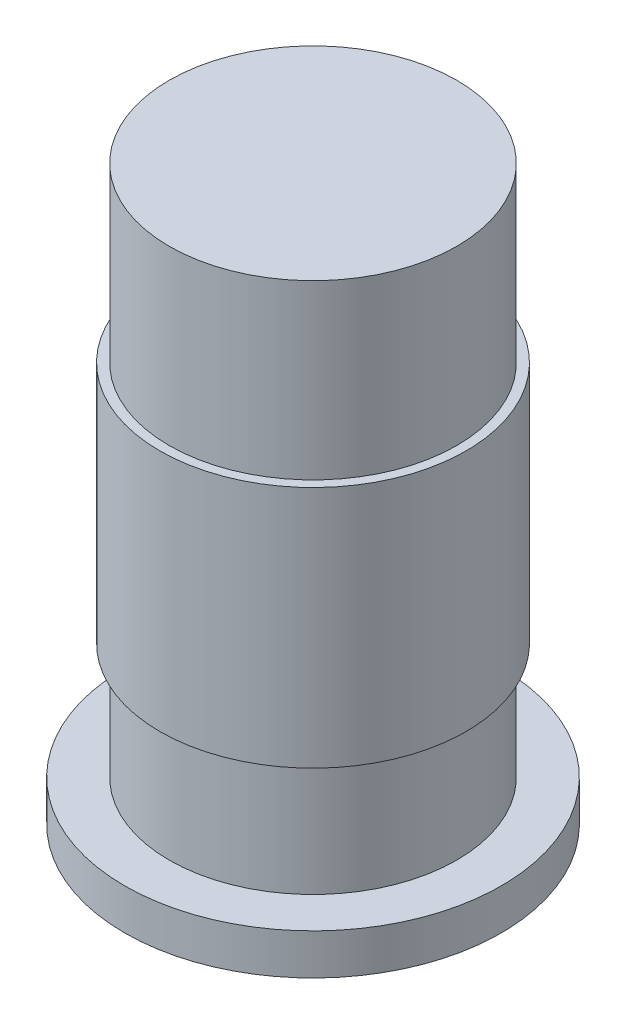
from build123d import *

# Parameters (mm, degrees)
CROQUIS1_R              = 101.5
SALIENTE_EXTRUIR1_DEPTH = 22
CROQUIS2_R              = 77.5
SALIENTE_EXTRUIR2_DEPTH = 286.5
CROQUIS3_R              = 82.5
SALIENTE_EXTRUIR3_DEPTH = 131


with BuildPart() as part:
    # Croquis1 → Saliente-Extruir1 (new body)
    with BuildSketch(Plane(origin=(0, 0, 0), x_dir=(1, 0, 0), z_dir=(0, 1, 0))):
        Circle(CROQUIS1_R)
    extrude(amount=SALIENTE_EXTRUIR1_DEPTH)

    # Croquis2 → Saliente-Extruir2 (add)
    with BuildSketch(Plane(origin=(0, 22, 0), x_dir=(1, 0, 0), z_dir=(0, 1, 0))):
        Circle(CROQUIS2_R)
    extrude(amount=SALIENTE_EXTRUIR2_DEPTH)

    # Croquis3 → Saliente-Extruir3 (add)
    with BuildSketch(Plane(origin=(0, 84.5, 0), x_dir=(1, 0, 0), z_dir=(0, 1, 0))):
        Circle(CROQUIS3_R)
    extrude(amount=SALIENTE_EXTRUIR3_DEPTH)


solid = part.part
